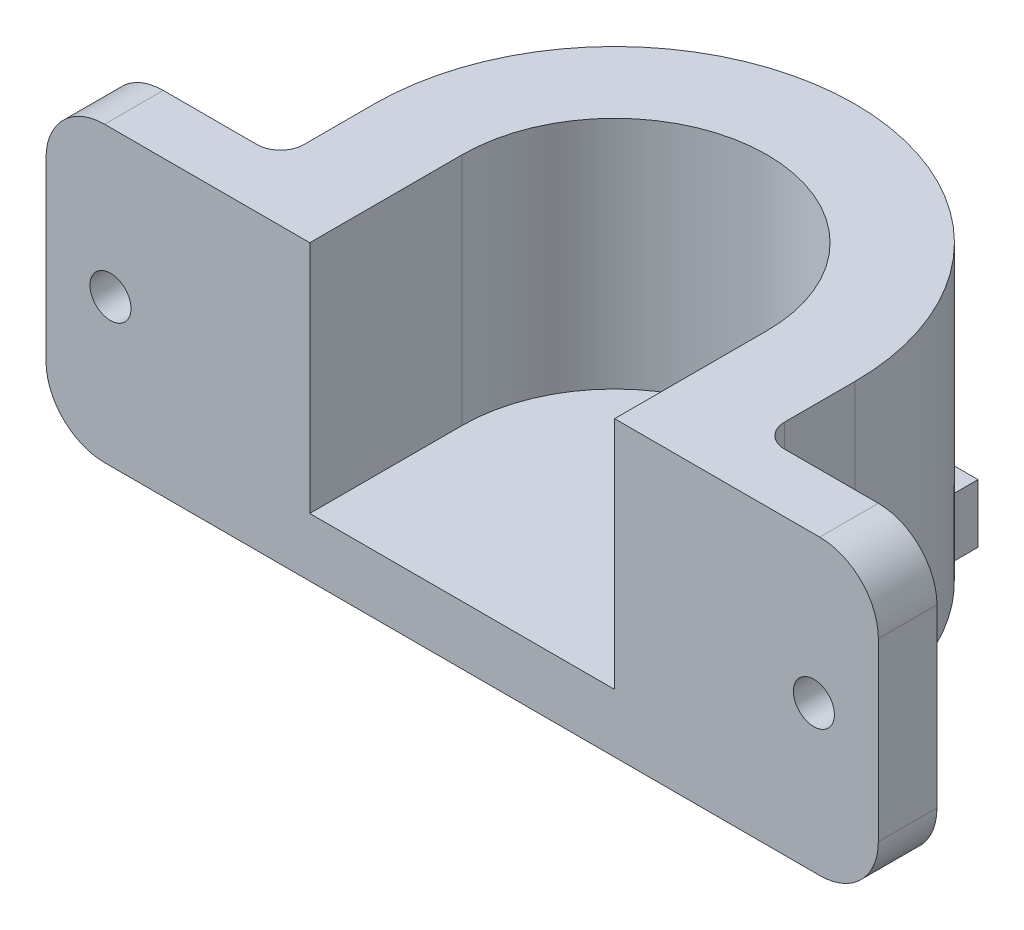
from build123d import *

# Parameters (mm, degrees)
BOSS_EXTRUDE1_DEPTH = 25
SKETCH4_R           = 1.75
CUT_EXTRUDE1_DEPTH  = 6
FILLET1_R           = 5
FILLET2_R           = 2
SKETCH5_W           = 26
SKETCH5_H           = 5
BOSS_EXTRUDE2_DEPTH = 31


with BuildPart() as part:
    # Sketch1 → Boss-Extrude1 (new body)
    with BuildSketch(Plane(origin=(0, 0, 0), x_dir=(1, 0, 0), z_dir=(0, 1, 0))):
        with BuildLine():
            Line((-7.5, 0), (-7.5, -8))
            Line((-7.5, -8), (-22.5, -8))
            Line((-22.5, -8), (-22.5, -13))
            Line((-22.5, -13), (0, -13))
            Line((0, -13), (0, 0))
            ThreePointArc((0, 0), (13, 13), (26, 0))
            Line((26, 0), (26, -13))
            Line((26, -13), (48.5, -13))
            Line((48.5, -13), (48.5, -8))
            Line((48.5, -8), (33.5, -8))
            Line((33.5, -8), (33.5, 0))
            ThreePointArc((33.5, 0), (13, 20.5), (-7.5, 0))
        make_face()
    extrude(amount=BOSS_EXTRUDE1_DEPTH)

    # Sketch4 → Cut-Extrude1 (cut, through all)
    with BuildSketch(Plane(origin=(0, 0, 8), x_dir=(-1, 0, 0), z_dir=(0, 0, -1))):
        with Locations((-43, 12.5)):
            Circle(SKETCH4_R)
        with Locations((17, 12.5)):
            Circle(SKETCH4_R)
    extrude(amount=-CUT_EXTRUDE1_DEPTH, mode=Mode.SUBTRACT)

    # Fillet1
    fillet1_edges = [part.edges().sort_by_distance(p)[0] for p in [
        (-22.5, 0, 10.5),
        (48.5, 0, 10.5),
        (48.5, 25, 10.5),
        (-22.5, 25, 10.5),
    ]]
    fillet(fillet1_edges, radius=FILLET1_R)

    # Fillet2
    fillet2_edges = [part.edges().sort_by_distance(p)[0] for p in [
        (-7.5, 12.5, 8),
        (33.5, 12.5, 8),
    ]]
    fillet(fillet2_edges, radius=FILLET2_R)

    # Sketch5 → Boss-Extrude2 (add)
    with BuildSketch(Plane.XY.offset(13)):
        with Locations((13, 2.5)):
            Rectangle(SKETCH5_W, SKETCH5_H)
    extrude(amount=-BOSS_EXTRUDE2_DEPTH)


solid = part.part
